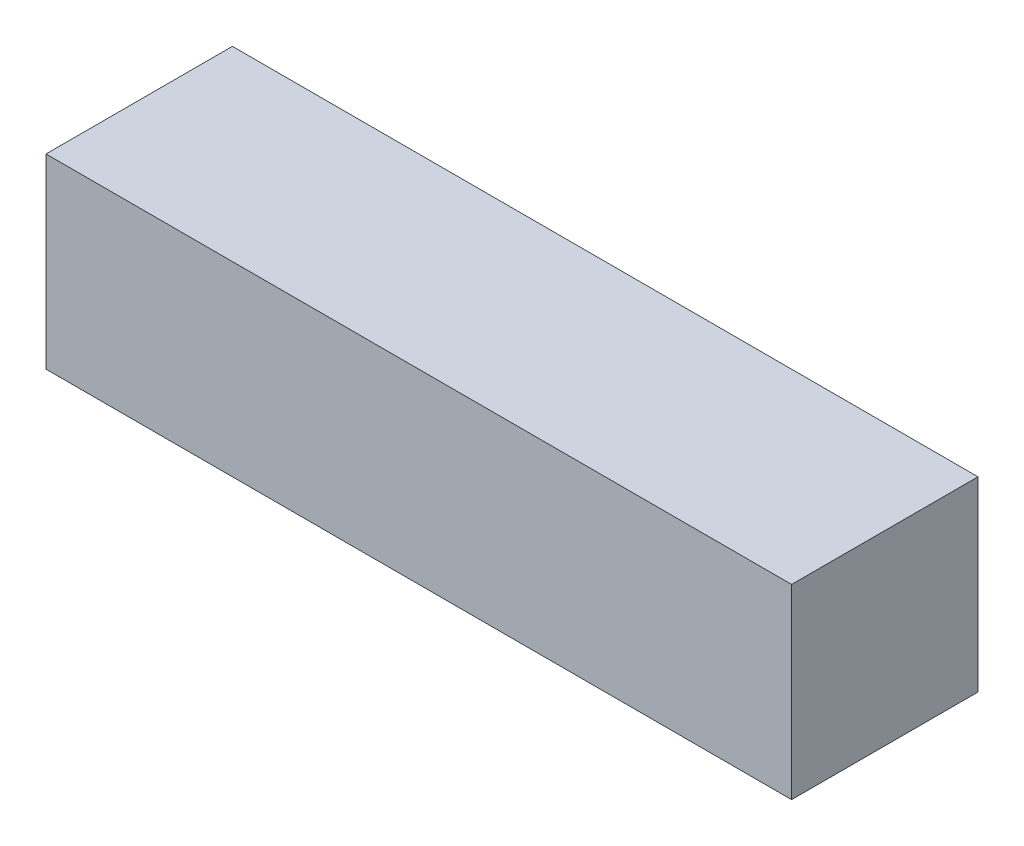
from build123d import *

# Parameters (mm, degrees)
SKETCH3_W           = 12.7
SKETCH3_H           = 3.175
EXTRUDE1_DEPTH      = 1.5875
EXTRUDE1_DEPTH_BACK = 1.5875


with BuildPart() as part:
    # Sketch3 → Extrude1 (new body, two sides)
    with BuildSketch(Plane(origin=(0, 0, 0), x_dir=(1, 0, 0), z_dir=(0, 1, 0))) as extrude1_sk:
        Rectangle(SKETCH3_W, SKETCH3_H)
    extrude(amount=EXTRUDE1_DEPTH)
    extrude(extrude1_sk.sketch, amount=-EXTRUDE1_DEPTH_BACK)


solid = part.part
